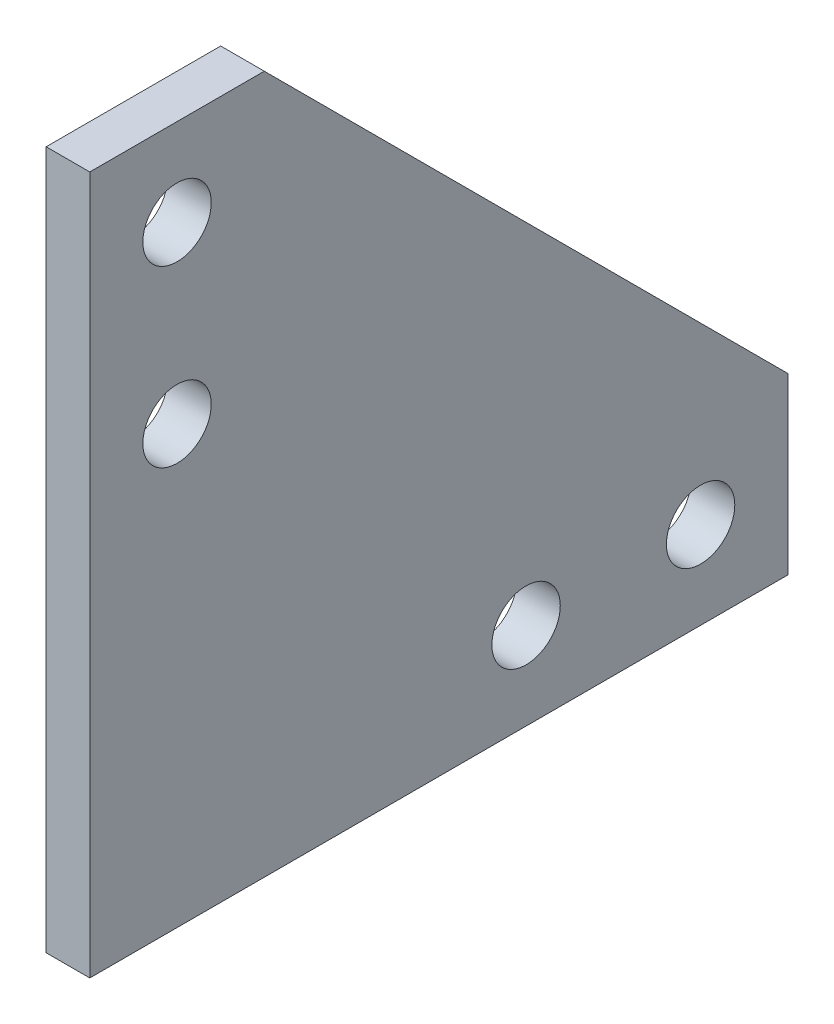
from build123d import *

# Parameters (mm, degrees)
SKETCH3_R           = 2.4892
BOSS_EXTRUDE1_DEPTH = 3.175


with BuildPart() as part:
    # Sketch3 → Boss-Extrude1 (new body)
    with BuildSketch(Plane(origin=(0, 0, 0), x_dir=(0, 0, -1), z_dir=(1, 0, 0))):
        Polygon((0, 0), (50.8, 0), (50.8, 12.7), (12.7, 50.8), (0, 50.8), align=None)
        with Locations((6.35, 44.45)):
            Circle(SKETCH3_R, mode=Mode.SUBTRACT)
        with Locations((6.35, 31.75)):
            Circle(SKETCH3_R, mode=Mode.SUBTRACT)
        with Locations((31.75, 6.35)):
            Circle(SKETCH3_R, mode=Mode.SUBTRACT)
        with Locations((44.45, 6.35)):
            Circle(SKETCH3_R, mode=Mode.SUBTRACT)
    extrude(amount=BOSS_EXTRUDE1_DEPTH)


solid = part.part
